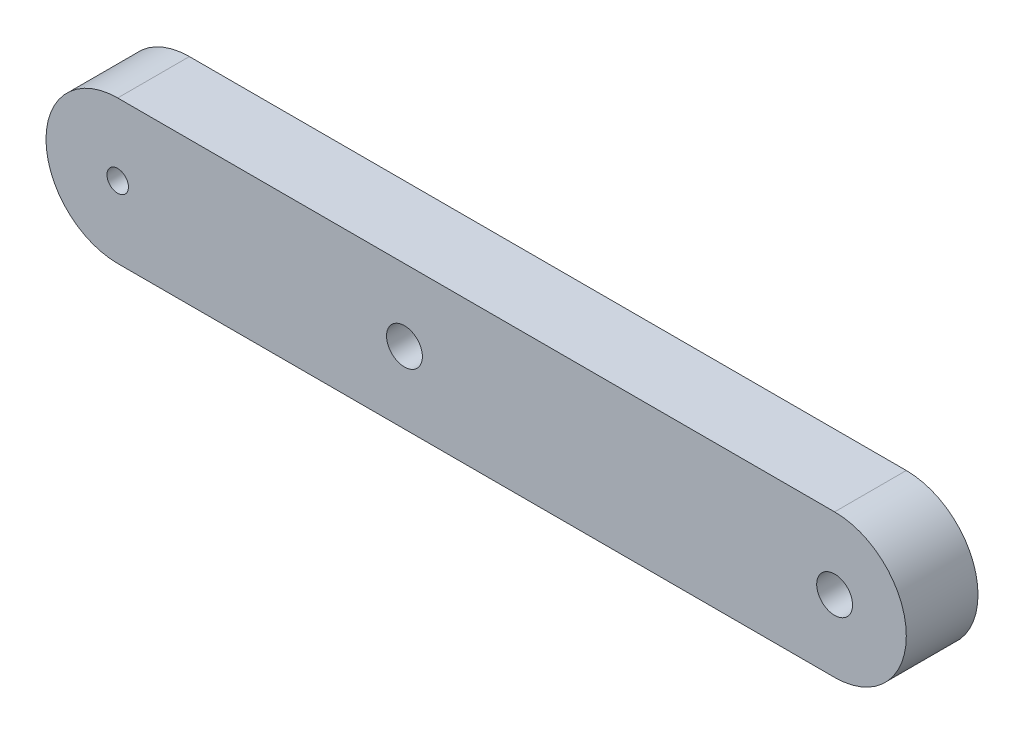
from build123d import *

# Parameters (mm, degrees)
ESQUISSE1_R        = 2.5
ESQUISSE1_R_2      = 1.5
BOSS_EXTRU_1_DEPTH = 10


with BuildPart() as part:
    # Esquisse1 → Boss.-Extru.1 (new body)
    with BuildSketch(Plane.XY):
        with BuildLine():
            Line((-40, 0), (60, 0))
            ThreePointArc((60, 0), (70, 10), (60, 20))
            Line((60, 20), (-40, 20))
            ThreePointArc((-40, 20), (-50, 10), (-40, 0))
        make_face()
        with Locations((0, 10)):
            Circle(ESQUISSE1_R, mode=Mode.SUBTRACT)
        with Locations((60, 10)):
            Circle(ESQUISSE1_R, mode=Mode.SUBTRACT)
        with Locations((-40, 9.983582118)):
            Circle(ESQUISSE1_R_2, mode=Mode.SUBTRACT)
    extrude(amount=BOSS_EXTRU_1_DEPTH)


solid = part.part
